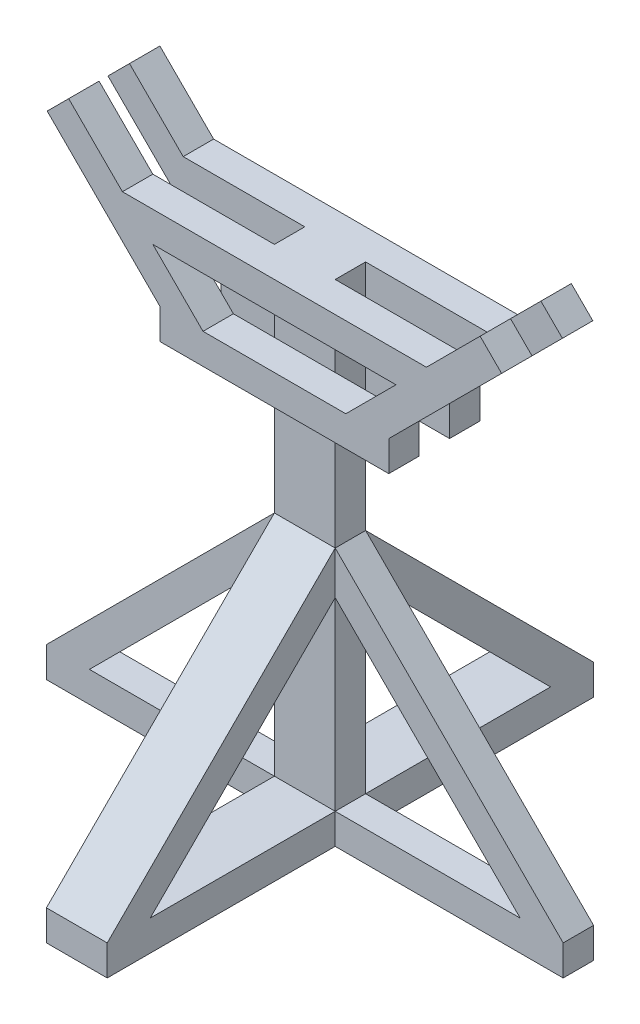
from build123d import *

# Parameters (mm, degrees)
SKETCH_1_W          = 80
SKETCH_1_H          = 40
EXTRUDE_1_DEPTH     = 500
SKETCH_2_W          = 400
SKETCH_2_H          = 40
EXTRUDE_2_DEPTH     = 40
SKETCH_3_W          = 400
SKETCH_3_H          = 40
EXTRUDE_3_DEPTH     = 40
CUT_EXTRUDE_1_DEPTH = 121
SKETCH_5_W          = 40
SKETCH_5_H          = 150
EXTRUDE_4_DEPTH     = 40
SKETCH_6_W          = 40
SKETCH_6_H          = 40
EXTRUDE_5_DEPTH     = 100
SKETCH_7_W          = 40
SKETCH_7_H          = 150
EXTRUDE_6_DEPTH     = 40
SKETCH_8_W          = 40
SKETCH_8_H          = 40
EXTRUDE_7_DEPTH     = 100
SKETCH_9_W          = 40
SKETCH_9_H          = 150
EXTRUDE_8_DEPTH     = 40
SKETCH_10_W         = 40
SKETCH_10_H         = 40
EXTRUDE_9_DEPTH     = 100
CUT_EXTRUDE_2_DEPTH = 121
SKETCH_13_W         = 301.005050634
SKETCH_13_H         = 40
EXTRUDE_10_DEPTH    = 40
SKETCH_14_W         = 40
SKETCH_14_H         = 40
EXTRUDE_11_DEPTH    = 500
SKETCH_15_W         = 80
SKETCH_15_H         = 40
EXTRUDE_12_DEPTH    = 146.066017
EXTRUDE_13_REACH    = 411.497
SKETCH_17_W         = 40
SKETCH_17_H         = 40
CUT_EXTRUDE_3_DEPTH = 500
SKETCH_19_W         = 80
SKETCH_19_H         = 40
EXTRUDE_14_DEPTH    = 500
SKETCH_20_W         = 80
SKETCH_20_H         = 40
EXTRUDE_15_DEPTH    = 300
SKETCH_21_W         = 40
SKETCH_21_H         = 40
EXTRUDE_16_DEPTH    = 300
SKETCH_22_W         = 80
SKETCH_22_H         = 40
EXTRUDE_17_DEPTH    = 300
SKETCH_23_W         = 40
SKETCH_23_H         = 40
EXTRUDE_18_DEPTH    = 300
EXTRUDE_19_DEPTH    = 40
EXTRUDE_20_DEPTH    = 40
EXTRUDE_21_DEPTH    = 80
EXTRUDE_22_DEPTH    = 80


with BuildPart() as part:
    # 草图1 → 凸台-拉伸1 (new body)
    with BuildSketch(Plane(origin=(0, 0, 0), x_dir=(1, 0, 0), z_dir=(0, 1, 0))):
        with Locations((40, -20)):
            Rectangle(SKETCH_1_W, SKETCH_1_H)
    extrude(amount=EXTRUDE_1_DEPTH)

    # 草图2 → 凸台-拉伸2 (add)
    with BuildSketch(Plane.XY.offset(40)):
        with Locations((40, 480)):
            Rectangle(SKETCH_2_W, SKETCH_2_H)
    extrude(amount=EXTRUDE_2_DEPTH)

    # 草图3 → 凸台-拉伸3 (add)
    with BuildSketch(Plane(origin=(0, 0, 0), x_dir=(-1, 0, 0), z_dir=(0, 0, -1))):
        with Locations((-40, 480)):
            Rectangle(SKETCH_3_W, SKETCH_3_H)
    extrude(amount=EXTRUDE_3_DEPTH)

    # 草图4 → 切除-拉伸1 (cut, through all)
    with BuildSketch(Plane.XY.offset(80)):
        Polygon((-160, 500), (-120, 460), (-160, 460), align=None)
        Polygon((240, 500), (200, 460), (240, 460), align=None)
    extrude(amount=-CUT_EXTRUDE_1_DEPTH, mode=Mode.SUBTRACT)

    # 草图5 → 凸台-拉伸4 (add)
    with BuildSketch(Plane(origin=(-130, 130, 0), x_dir=(0, 0, -1), z_dir=(0.707106781, -0.707106781, 0))):
        with Locations((-60, 448.259018078)):
            Rectangle(SKETCH_5_W, SKETCH_5_H)
    extrude(amount=EXTRUDE_4_DEPTH)

    # 草图6 → 凸台-拉伸5 (add)
    with BuildSketch(Plane(origin=(370, 370, 0), x_dir=(0, 0, -1), z_dir=(0.707106781, 0.707106781, 0))):
        with Locations((-60, 163.847763108)):
            Rectangle(SKETCH_6_W, SKETCH_6_H)
    extrude(amount=EXTRUDE_5_DEPTH)

    # 草图7 → 凸台-拉伸6 (add)
    with BuildSketch(Plane(origin=(-130, 130, 0), x_dir=(0, 0, -1), z_dir=(0.707106781, -0.707106781, 0))):
        with Locations((20, 448.259018078)):
            Rectangle(SKETCH_7_W, SKETCH_7_H)
    extrude(amount=EXTRUDE_6_DEPTH)

    # 草图8 → 凸台-拉伸7 (add)
    with BuildSketch(Plane(origin=(370, 370, 0), x_dir=(0, 0, -1), z_dir=(0.707106781, 0.707106781, 0))):
        with Locations((20, 163.847763108)):
            Rectangle(SKETCH_8_W, SKETCH_8_H)
    extrude(amount=EXTRUDE_7_DEPTH)

    # 草图9 → 凸台-拉伸8 (add)
    with BuildSketch(Plane(origin=(170, 170, 0), x_dir=(0, 0, 1), z_dir=(-0.707106781, -0.707106781, 0))):
        with Locations((-20, 391.690475583)):
            Rectangle(SKETCH_9_W, SKETCH_9_H)
        with Locations((60, 391.690475583)):
            Rectangle(SKETCH_9_W, SKETCH_9_H)
    extrude(amount=EXTRUDE_8_DEPTH)

    # 草图10 → 凸台-拉伸9 (add)
    with BuildSketch(Plane(origin=(-330, 330, 0), x_dir=(0, 0, 1), z_dir=(-0.707106781, 0.707106781, 0))):
        with Locations((-20, 220.416305603)):
            Rectangle(SKETCH_10_W, SKETCH_10_H)
        with Locations((60, 220.416305603)):
            Rectangle(SKETCH_10_W, SKETCH_10_H)
    extrude(amount=EXTRUDE_9_DEPTH)

    # 草图12 → 切除-拉伸2 (cut, through all)
    with BuildSketch(Plane.XY.offset(80)):
        Polygon((-82.218254069, 365.649711575), (-53.933982822, 393.933982822), (-110.502525317, 393.933982822), align=None)
        Polygon((133.933982822, 393.933982822), (162.218254069, 365.649711575), (190.502525317, 393.933982822), align=None)
    extrude(amount=-CUT_EXTRUDE_2_DEPTH, mode=Mode.SUBTRACT)

    # 草图13 → 凸台-拉伸10 (add)
    with BuildSketch(Plane.XZ.offset(-393.933982822)):
        with Locations((40, 60)):
            Rectangle(SKETCH_13_W, SKETCH_13_H)
        with Locations((40, -20)):
            Rectangle(SKETCH_13_W, SKETCH_13_H)
    extrude(amount=EXTRUDE_10_DEPTH)

    # 草图14 → 凸台-拉伸11 (add)
    with BuildSketch(Plane(origin=(0, 353.933982822, 0), x_dir=(-1, 0, 0), z_dir=(0, -1, 0))):
        with Locations((90.502525317, -60)):
            Rectangle(SKETCH_14_W, SKETCH_14_H)
        with Locations((90.502525317, 20)):
            Rectangle(SKETCH_14_W, SKETCH_14_H)
        with Locations((-170.502525317, -60)):
            Rectangle(SKETCH_14_W, SKETCH_14_H)
        with Locations((-170.502525317, 20)):
            Rectangle(SKETCH_14_W, SKETCH_14_H)
    extrude(amount=EXTRUDE_11_DEPTH)

    # 草图15 → 凸台-拉伸12 (add)
    with BuildSketch(Plane.XZ):
        with Locations((40, 20)):
            Rectangle(SKETCH_15_W, SKETCH_15_H)
    extrude(amount=EXTRUDE_12_DEPTH)

    # 草图17 → 凸台-拉伸13 (add, up to next)
    with BuildSketch(Plane(origin=(-70.502525317, 0, 0), x_dir=(0, 0, -1), z_dir=(1, 0, 0)), mode=Mode.PRIVATE) as extrude_13_sk1:
        with Locations((-60, -126.066017178)):
            Rectangle(SKETCH_17_W, SKETCH_17_H)
    extrude_13_tool1 = extrude(extrude_13_sk1.sketch, amount=EXTRUDE_13_REACH, mode=Mode.PRIVATE) - part.part
    add(extrude_13_tool1.solids().sort_by_distance((-70.502525, -126.066017, 60))[0])
    # 草图17 → 凸台-拉伸13 (add, up to next)
    with BuildSketch(Plane(origin=(-70.502525317, 0, 0), x_dir=(0, 0, -1), z_dir=(1, 0, 0)), mode=Mode.PRIVATE) as extrude_13_sk2:
        with Locations((20, -126.066017178)):
            Rectangle(SKETCH_17_W, SKETCH_17_H)
    extrude_13_tool2 = extrude(extrude_13_sk2.sketch, amount=EXTRUDE_13_REACH, mode=Mode.PRIVATE) - part.part
    add(extrude_13_tool2.solids().sort_by_distance((-70.502525, -126.066017, -20))[0])

    # 草图18 → 切除-拉伸3 (cut)
    with BuildSketch(Plane.XZ.offset(146.066017178)):
        Polygon((-110.502525317, 80), (-110.502525317, 40), (0, 40), (0, 0), (-110.502525317, 0), (-110.502525317, -40), (190.502525317, -40), (190.502525317, 0), (80, 0), (80, 40), (190.502525317, 40), (190.502525317, 80), align=None)
    extrude(amount=-CUT_EXTRUDE_3_DEPTH, mode=Mode.SUBTRACT)

    # 草图19 → 凸台-拉伸14 (add)
    with BuildSketch(Plane.XZ.offset(-353.933982822)):
        with Locations((40, 20)):
            Rectangle(SKETCH_19_W, SKETCH_19_H)
    extrude(amount=EXTRUDE_14_DEPTH)

    # 草图20 → 凸台-拉伸15 (add)
    with BuildSketch(Plane.XY.offset(40)):
        with Locations((40, -126.066017178)):
            Rectangle(SKETCH_20_W, SKETCH_20_H)
    extrude(amount=EXTRUDE_15_DEPTH)

    # 草图21 → 凸台-拉伸16 (add)
    with BuildSketch(Plane(origin=(80, 0, 0), x_dir=(0, 0, -1), z_dir=(1, 0, 0))):
        with Locations((-20, -126.066017178)):
            Rectangle(SKETCH_21_W, SKETCH_21_H)
    extrude(amount=EXTRUDE_16_DEPTH)

    # 草图22 → 凸台-拉伸17 (add)
    with BuildSketch(Plane(origin=(0, 0, 0), x_dir=(-1, 0, 0), z_dir=(0, 0, -1))):
        with Locations((-40, -126.066017178)):
            Rectangle(SKETCH_22_W, SKETCH_22_H)
    extrude(amount=EXTRUDE_17_DEPTH)

    # 草图23 → 凸台-拉伸18 (add)
    with BuildSketch(Plane.ZY):
        with Locations((20, -126.066017178)):
            Rectangle(SKETCH_23_W, SKETCH_23_H)
    extrude(amount=EXTRUDE_18_DEPTH)

    # 草图24 → 凸台-拉伸19 (add)
    with BuildSketch(Plane.XY.offset(40)):
        Polygon((-243.431457505, -106.066017178), (0, 137.365440327), (0, 193.933982822), (-300, -106.066017178), align=None)
    extrude(amount=-EXTRUDE_19_DEPTH)

    # 草图25 → 凸台-拉伸20 (add)
    with BuildSketch(Plane.XY.offset(40)):
        Polygon((380, -106.066017178), (80, 193.933982822), (80, 137.365440327), (323.431457505, -106.066017178), align=None)
    extrude(amount=-EXTRUDE_20_DEPTH)

    # 草图26 → 凸台-拉伸21 (add)
    with BuildSketch(Plane.ZY):
        Polygon((-300, -106.066017178), (0, 193.933982822), (0, 137.365440327), (-243.431457505, -106.066017178), align=None)
    extrude(amount=-EXTRUDE_21_DEPTH)

    # 草图27 → 凸台-拉伸22 (add)
    with BuildSketch(Plane.ZY):
        Polygon((340, -106.066017178), (40, 193.933982822), (40, 137.365440327), (283.431457505, -106.066017178), align=None)
    extrude(amount=-EXTRUDE_22_DEPTH)


solid = part.part
